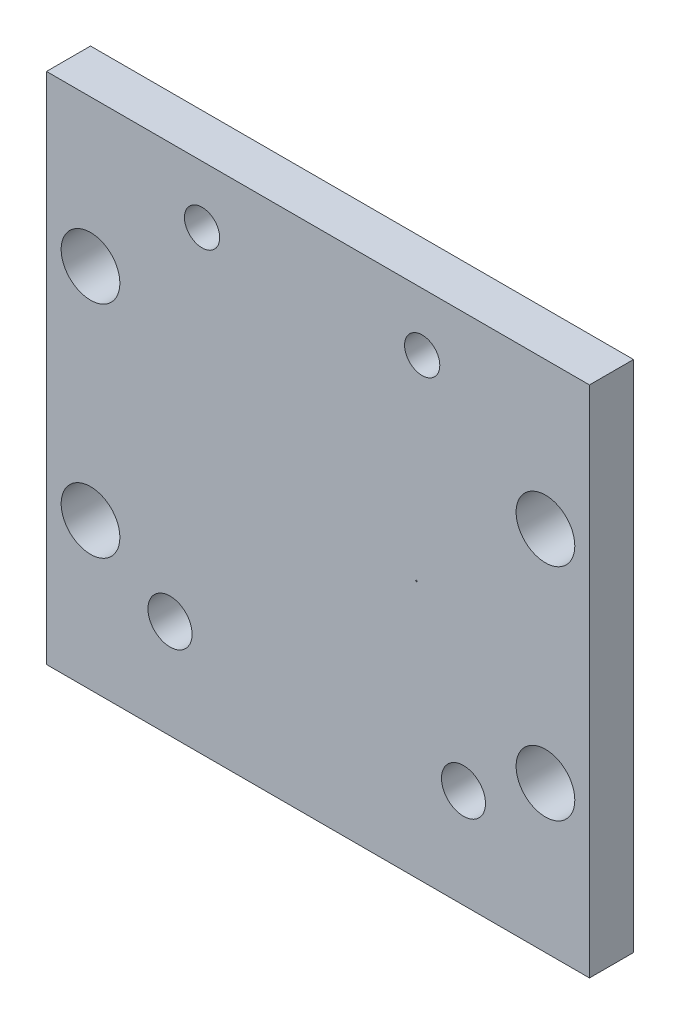
from build123d import *

# Parameters (mm, degrees)
SKETCH1_W           = 37
SKETCH1_H           = 35
SKETCH1_R           = 1.5
SKETCH1_R_2         = 0.050923396
SKETCH1_R_3         = 1.504485308
SKETCH1_R_4         = 1.2
SKETCH1_R_5         = 2
BOSS_EXTRUDE1_DEPTH = 3


with BuildPart() as part:
    # Sketch1 → Boss-Extrude1 (new body)
    with BuildSketch(Plane.XY):
        with Locations((0.030567594, 5.922615255)):
            Rectangle(SKETCH1_W, SKETCH1_H)
        with Locations((9.945509842, -4.827384745)):
            Circle(SKETCH1_R, mode=Mode.SUBTRACT)
        with Locations((6.740243031, 5.953835455)):
            Circle(SKETCH1_R_2, mode=Mode.SUBTRACT)
        with Locations((-10.052008632, -4.831121055)):
            Circle(SKETCH1_R_3, mode=Mode.SUBTRACT)
        with Locations((-7.869157906, 19.508358976)):
            Circle(SKETCH1_R_4, mode=Mode.SUBTRACT)
        with Locations((7.130801552, 19.473483987)):
            Circle(SKETCH1_R_4, mode=Mode.SUBTRACT)
        with Locations((-15.469432406, -1.577384745)):
            Circle(SKETCH1_R_5, mode=Mode.SUBTRACT)
        with Locations((15.530567594, -1.577384745)):
            Circle(SKETCH1_R_5, mode=Mode.SUBTRACT)
        with Locations((-15.469432406, 13.422615255)):
            Circle(SKETCH1_R_5, mode=Mode.SUBTRACT)
        with Locations((15.530567594, 13.422615255)):
            Circle(SKETCH1_R_5, mode=Mode.SUBTRACT)
    extrude(amount=BOSS_EXTRUDE1_DEPTH)


solid = part.part
